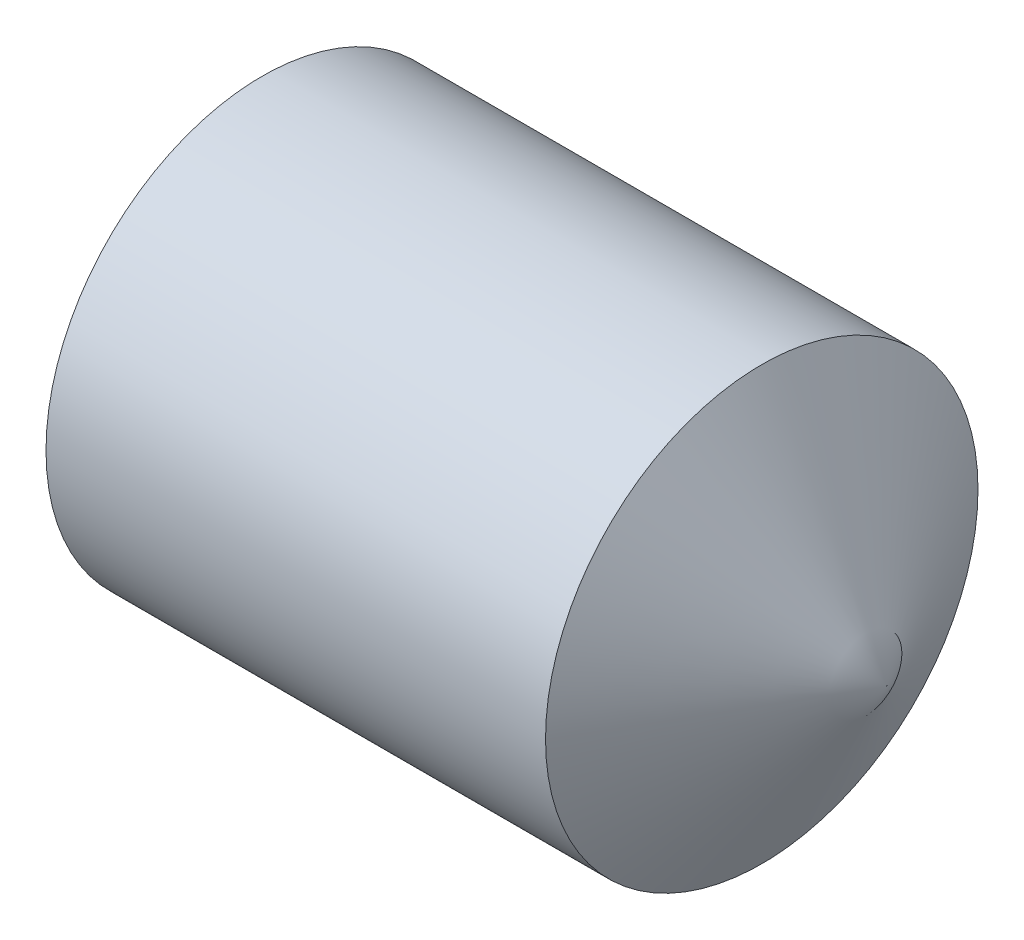
from build123d import *

# Parameters (mm, degrees)
HEX_2_DEPTH = 1.5


with BuildPart() as part:
    # BodySke → BaseBody (revolve)
    with BuildSketch(Plane.XY, mode=Mode.PRIVATE) as basebody_sk:
        Polygon((0, 0), (0, 1.61), (0.225166605, 2), (4.845299462, 2), (6, 0), align=None)
    revolve(basebody_sk.sketch.rotate(Axis((-12.7, 0, 0), (1, 0, 0)), 90), axis=Axis((-12.7, 0, 0), (1, 0, 0)))  # turned: the seam where the file's is

    # Sketch2 → Hex 2 (cut)
    with BuildSketch(Plane.ZY):
        Polygon((0.577350269, 1), (-0.577350269, 1), (-1.154700538, 0), (-0.577350269, -1), (0.577350269, -1), (1.154700538, 0), align=None)
    extrude(amount=-HEX_2_DEPTH, mode=Mode.SUBTRACT)


solid = part.part
